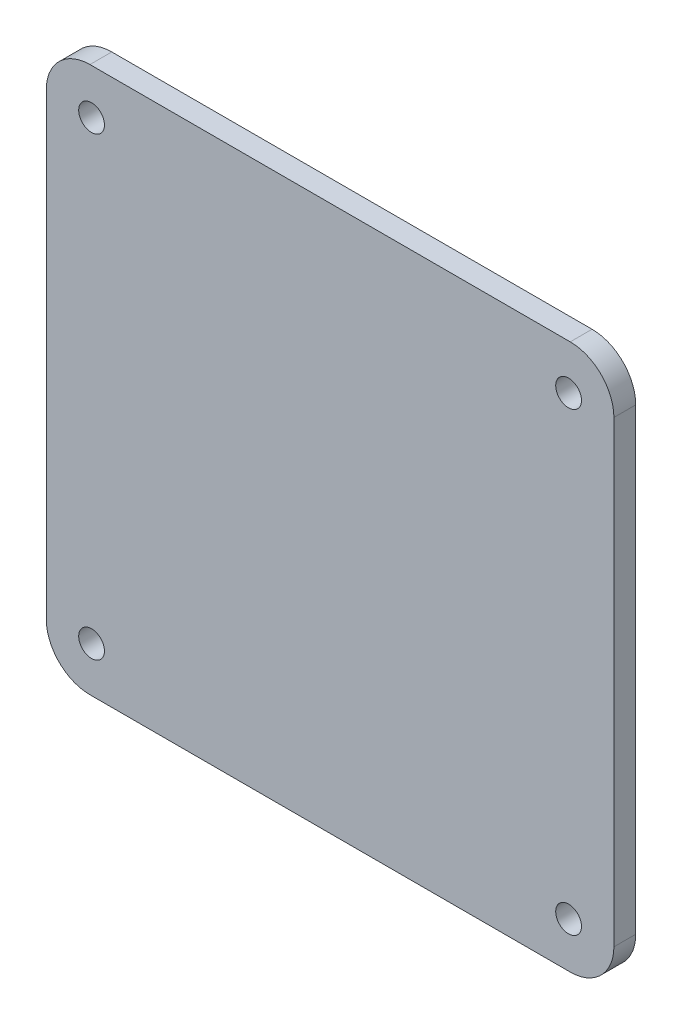
from build123d import *

# Parameters (mm, degrees)
BOSS_EXTRUDE1_DEPTH = 2.54
SKETCH2_R           = 1.5
CUT_EXTRUDE1_DEPTH  = 3.54


with BuildPart() as part:
    # Sketch1 → Boss-Extrude1 (new body)
    with BuildSketch(Plane.XY):
        with BuildLine():
            Line((-27.94, -31.75), (27.94, -31.75))
            ThreePointArc((27.94, -31.75), (31.532102448, -30.262102448), (33.02, -26.67))
            Line((33.02, -26.67), (33.02, 26.67))
            ThreePointArc((33.02, 26.67), (31.532102448, 30.262102448), (27.94, 31.75))
            Line((27.94, 31.75), (-27.94, 31.75))
            ThreePointArc((-27.94, 31.75), (-31.532102448, 30.262102448), (-33.02, 26.67))
            Line((-33.02, 26.67), (-33.02, -26.67))
            ThreePointArc((-33.02, -26.67), (-31.532102448, -30.262102448), (-27.94, -31.75))
        make_face()
    extrude(amount=BOSS_EXTRUDE1_DEPTH)

    # Sketch2 → Cut-Extrude1 (cut, through all)
    with BuildSketch(Plane.XY.offset(2.54)):
        with Locations((-27.75, 26.5)):
            Circle(SKETCH2_R)
        with Locations((27.75, 26.5)):
            Circle(SKETCH2_R)
        with Locations((-27.75, -26.5)):
            Circle(SKETCH2_R)
        with Locations((27.75, -26.5)):
            Circle(SKETCH2_R)
    extrude(amount=-CUT_EXTRUDE1_DEPTH, mode=Mode.SUBTRACT)


solid = part.part
